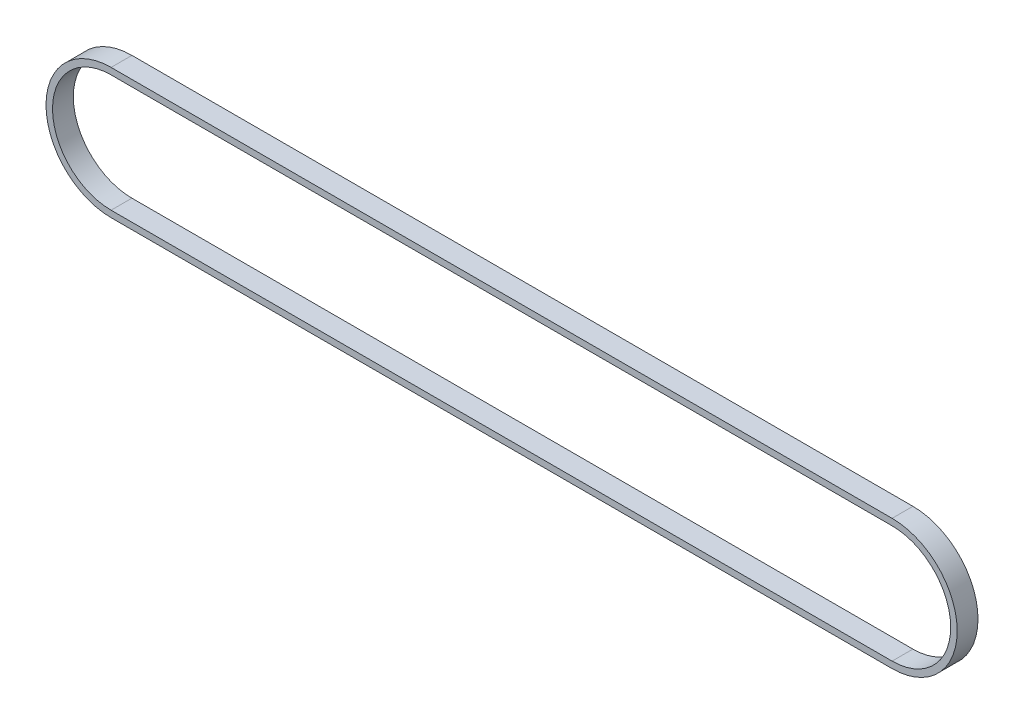
from build123d import *

# Parameters (mm, degrees)
BOSS_EXTRUDE1_DEPTH = 2


with BuildPart() as part:
    # Sketch1 → Boss-Extrude1 (new body, symmetric)
    with BuildSketch(Plane.XY):
        with BuildLine():
            Line((-75, 12.5), (75, 12.5))
            ThreePointArc((75, 12.5), (87.5, 0), (75, -12.5))
            Line((75, -12.5), (-75, -12.5))
            ThreePointArc((-75, -12.5), (-87.5, 0), (-75, 12.5))
        make_face()
        with BuildLine():
            Line((-75, 11.25), (75, 11.25))
            ThreePointArc((75, 11.25), (86.25, 0), (75, -11.25))
            Line((75, -11.25), (-75, -11.25))
            ThreePointArc((-75, -11.25), (-86.25, 0), (-75, 11.25))
        make_face(mode=Mode.SUBTRACT)
    extrude(amount=BOSS_EXTRUDE1_DEPTH, both=True)


solid = part.part
